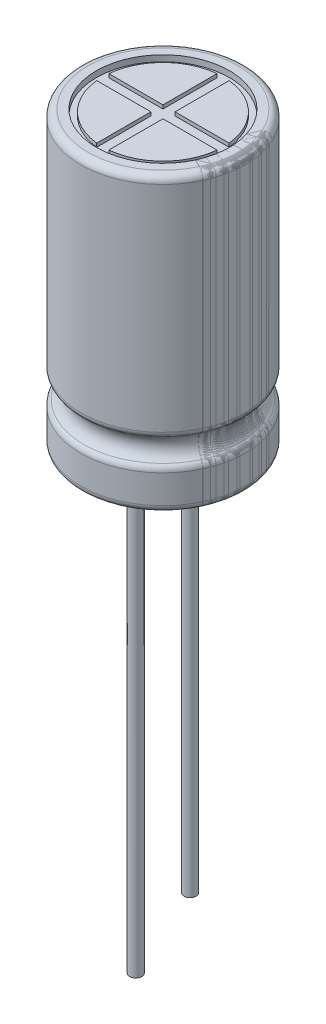
from build123d import *

# Parameters (mm, degrees)
BOSS_EXTRUDE1_DEPTH      = 0.15
BOSS_EXTRUDE1_2_DEPTH    = 0.15
BOSS_EXTRUDE1_3_DEPTH    = 0.15
BOSS_EXTRUDE1_4_DEPTH    = 0.15
SKETCH3_R                = 1.8
SKETCH3_RX               = 1.67
SKETCH3_RY               = 0.9
BOSS_EXTRUDE2_DEPTH      = 0.6
REVOLVE3_ANGLE           = 25
REVOLVE3_OTHER_WAY_ANGLE = 25
SKETCH7_R                = 0.25
BOSS_EXTRUDE3_DEPTH      = 19.6
SKETCH7_4_R              = 0.25
BOSS_EXTRUDE4_DEPTH      = 15.6


with BuildPart() as part:
    # Sketch1 → Revolve1 (revolve)
    with BuildSketch(Plane.XY, mode=Mode.PRIVATE) as revolve1_sk:
        with BuildLine():
            Line((0, 0.6), (2.8, 0.6))
            Line((2.8, 0.6), (2.8, 0.4))
            Line((2.8, 0.4), (3.1, 0.4))
            ThreePointArc((3.1, 0.4), (3.312132034, 0.487867966), (3.4, 0.7))
            Line((3.4, 0.7), (3.4, 1.873479579))
            ThreePointArc((3.4, 1.873479579), (3.365540419, 2.013080031), (3.270078093, 2.120609995))
            ThreePointArc((3.270078093, 2.120609995), (3.0180522, 2.6), (3.270078093, 3.079390005))
            ThreePointArc((3.270078093, 3.079390005), (3.365540419, 3.186919969), (3.4, 3.326520421))
            Line((3.4, 3.326520421), (3.4, 12.2))
            ThreePointArc((3.4, 12.2), (3.312132034, 12.412132034), (3.1, 12.5))
            Line((3.1, 12.5), (2.75, 12.5))
            Line((2.75, 12.5), (2.75, 12.25))
            Line((2.75, 12.25), (0, 12.25))
            Line((0, 12.25), (0, 0.6))
        make_face()
    revolve(revolve1_sk.sketch.rotate(Axis((0, 12.25, 0), (0, -1, 0)), 180), axis=Axis((0, 12.25, 0), (0, -1, 0)))



with BuildPart() as body_2:
    # Sketch2 → Boss-Extrude1 (new body)
    with BuildSketch(Plane(origin=(0, 12.25, 0), x_dir=(1, 0, 0), z_dir=(0, 1, 0))):
        with BuildLine():
            Line((-0.25, 0.25), (-0.25, 2.487468593))
            ThreePointArc((-0.25, 2.487468593), (-1.767766953, 1.767766953), (-2.487468593, 0.25))
            Line((-2.487468593, 0.25), (-0.25, 0.25))
        make_face()
    extrude(amount=BOSS_EXTRUDE1_DEPTH)


with BuildPart() as body_3:
    # Sketch2 → Boss-Extrude1 2 (new body)
    with BuildSketch(Plane(origin=(0, 12.25, 0), x_dir=(1, 0, 0), z_dir=(0, 1, 0))):
        with BuildLine():
            Line((0.25, -2.487468593), (0.25, -0.25))
            Line((0.25, -0.25), (2.487468593, -0.25))
            ThreePointArc((2.487468593, -0.25), (1.767766953, -1.767766953), (0.25, -2.487468593))
        make_face()
    extrude(amount=BOSS_EXTRUDE1_2_DEPTH)


with BuildPart() as body_4:
    # Sketch2 → Boss-Extrude1 3 (new body)
    with BuildSketch(Plane(origin=(0, 12.25, 0), x_dir=(1, 0, 0), z_dir=(0, 1, 0))):
        with BuildLine():
            Line((-0.25, -2.487468593), (-0.25, -0.25))
            Line((-0.25, -0.25), (-2.487468593, -0.25))
            ThreePointArc((-2.487468593, -0.25), (-1.767766953, -1.767766953), (-0.25, -2.487468593))
        make_face()
    extrude(amount=BOSS_EXTRUDE1_3_DEPTH)


with BuildPart() as body_5:
    # Sketch2 → Boss-Extrude1 4 (new body)
    with BuildSketch(Plane(origin=(0, 12.25, 0), x_dir=(1, 0, 0), z_dir=(0, 1, 0))):
        with BuildLine():
            Line((0.25, 0.25), (0.25, 2.487468593))
            ThreePointArc((0.25, 2.487468593), (1.767766953, 1.767766953), (2.487468593, 0.25))
            Line((2.487468593, 0.25), (0.25, 0.25))
        make_face()
    extrude(amount=BOSS_EXTRUDE1_4_DEPTH)


with BuildPart() as body_6:
    # Sketch3 → Boss-Extrude2 (new body)
    with BuildSketch(Plane.XZ.offset(-0.6)):
        Circle(SKETCH3_R)
        with Locations(Location((0, 0), (0, 0, 180))):
            Ellipse(SKETCH3_RX, SKETCH3_RY, mode=Mode.SUBTRACT)
    extrude(amount=BOSS_EXTRUDE2_DEPTH)


with BuildPart() as body_7:
    # Sketch5 → Revolve3 (revolve)
    with BuildSketch(Plane.XY):
        with BuildLine():
            Line((2.75, 12.5), (3.1, 12.5))
            ThreePointArc((3.1, 12.5), (3.312132034, 12.412132034), (3.4, 12.2))
            Line((3.4, 12.2), (3.4, 3.326520421))
            ThreePointArc((3.4, 3.326520421), (3.365540419, 3.186919969), (3.270078093, 3.079390005))
            ThreePointArc((3.270078093, 3.079390005), (3.0180522, 2.6), (3.270078093, 2.120609995))
            ThreePointArc((3.270078093, 2.120609995), (3.365540419, 2.013080031), (3.4, 1.873479579))
            Line((3.4, 1.873479579), (3.4, 0.7))
            ThreePointArc((3.4, 0.7), (3.312132034, 0.487867966), (3.1, 0.4))
            Line((3.1, 0.4), (2.8, 0.4))
            Line((2.8, 0.4), (2.75, 12.5))
        make_face()
    revolve(axis=Axis((0, 0, 0), (0, 1, 0)), revolution_arc=REVOLVE3_ANGLE)

    # Sketch5 → Revolve3 other way (revolve)
    with BuildSketch(Plane.XY):
        with BuildLine():
            Line((2.75, 12.5), (3.1, 12.5))
            ThreePointArc((3.1, 12.5), (3.312132034, 12.412132034), (3.4, 12.2))
            Line((3.4, 12.2), (3.4, 3.326520421))
            ThreePointArc((3.4, 3.326520421), (3.365540419, 3.186919969), (3.270078093, 3.079390005))
            ThreePointArc((3.270078093, 3.079390005), (3.0180522, 2.6), (3.270078093, 2.120609995))
            ThreePointArc((3.270078093, 2.120609995), (3.365540419, 2.013080031), (3.4, 1.873479579))
            Line((3.4, 1.873479579), (3.4, 0.7))
            ThreePointArc((3.4, 0.7), (3.312132034, 0.487867966), (3.1, 0.4))
            Line((3.1, 0.4), (2.8, 0.4))
            Line((2.8, 0.4), (2.75, 12.5))
        make_face()
    revolve(axis=Axis((0, 0, 0), (0, -1, 0)), revolution_arc=REVOLVE3_OTHER_WAY_ANGLE)


with BuildPart() as part_1:
    add(part.part)

    add(body_6.part)  # Boss-Extrude3 merges body 6
    # Sketch7 → Boss-Extrude3 (add)
    with BuildSketch(Plane.XZ.offset(-0.6)):
        with Locations(Location((-1.125, 0, 0), (0, 0, 180))):
            Circle(SKETCH7_R)
    extrude(amount=BOSS_EXTRUDE3_DEPTH)

    # Sketch7_4 → Boss-Extrude4 (add)
    with BuildSketch(Plane.XZ.offset(-0.6)):
        with Locations(Location((1.125, 0, 0), (0, 0, 180))):
            Circle(SKETCH7_4_R)
    extrude(amount=BOSS_EXTRUDE4_DEPTH)


solid = Compound([body_2.part, body_3.part, body_4.part, body_5.part, body_7.part, part_1.part])
